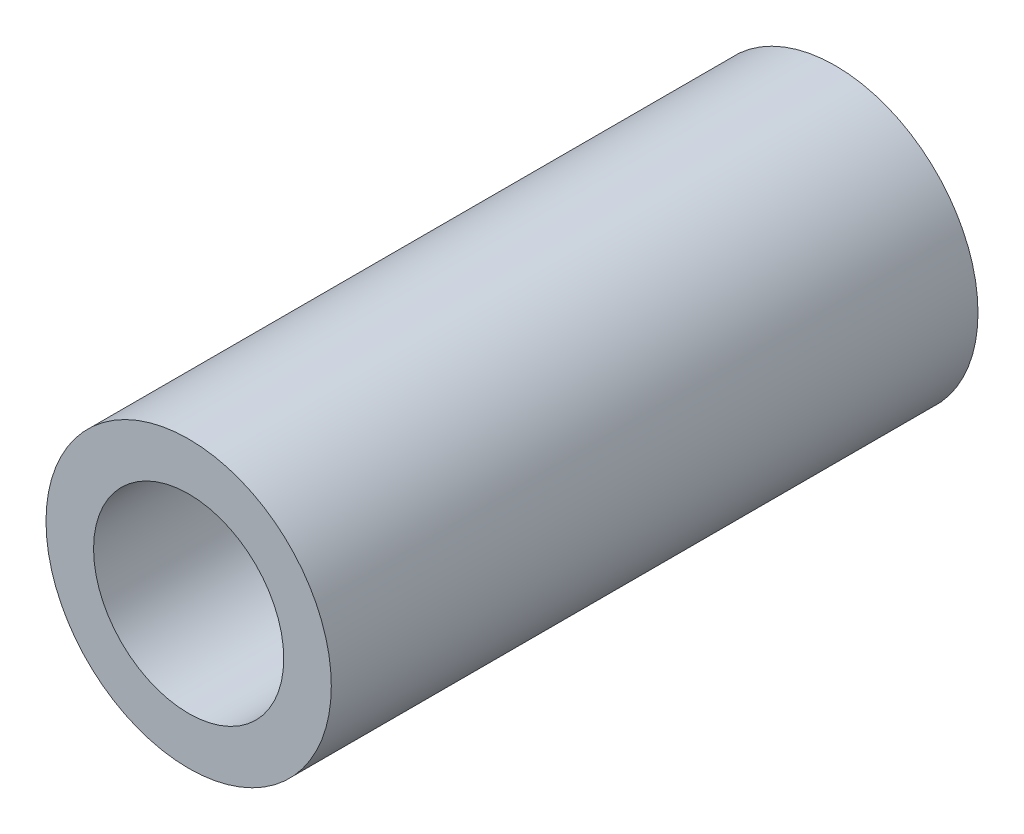
from build123d import *

# Parameters (mm, degrees)
SKETCH_1_R      = 1.5
SKETCH_1_R_2    = 1
EXTRUDE_1_DEPTH = 3.4


with BuildPart() as part:
    # Эскиз1 → Бобышка-Вытянуть1 (new, symmetric)
    with BuildSketch(Plane.XY):
        Circle(SKETCH_1_R)
        Circle(SKETCH_1_R_2, mode=Mode.SUBTRACT)
    extrude(amount=EXTRUDE_1_DEPTH, both=True)


solid = part.part
